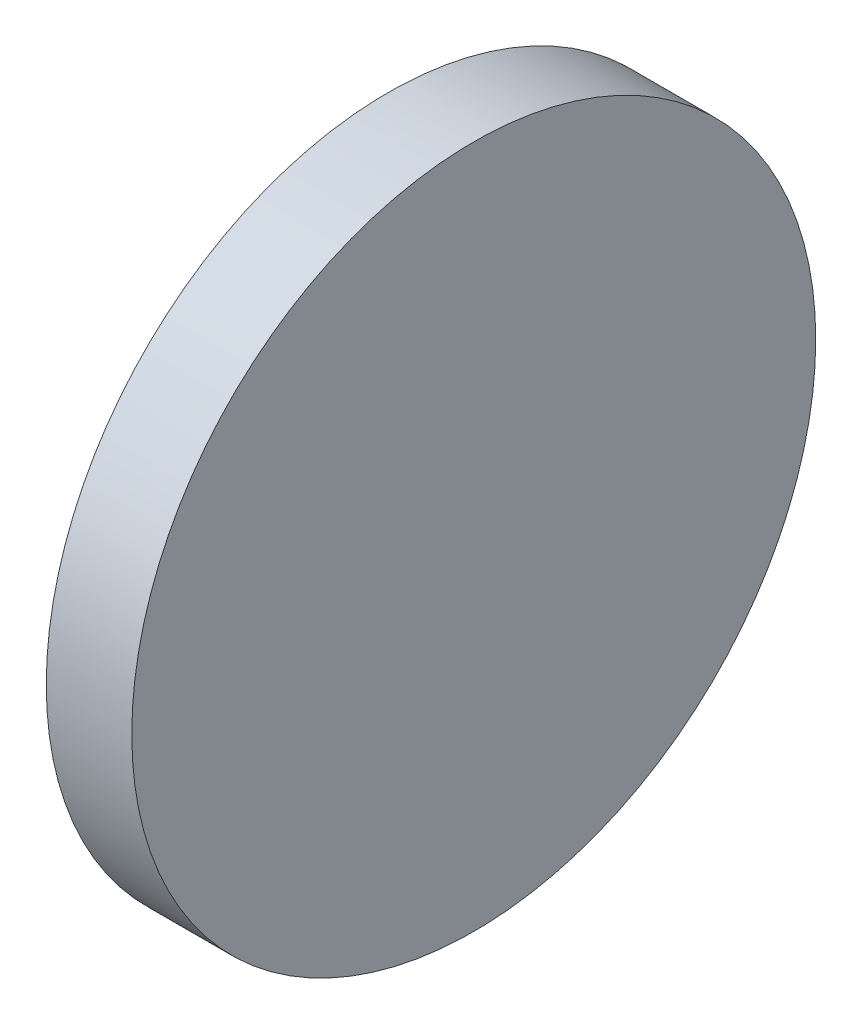
from build123d import *

# Parameters (mm, degrees)
SKETCH1_R           = 20
BOSS_EXTRUDE1_DEPTH = 5


with BuildPart() as part:
    # Sketch1 → Boss-Extrude1 (new body)
    with BuildSketch(Plane(origin=(0, 0, 0), x_dir=(0, 0, -1), z_dir=(1, 0, 0))):
        Circle(SKETCH1_R)
    extrude(amount=BOSS_EXTRUDE1_DEPTH)


solid = part.part
